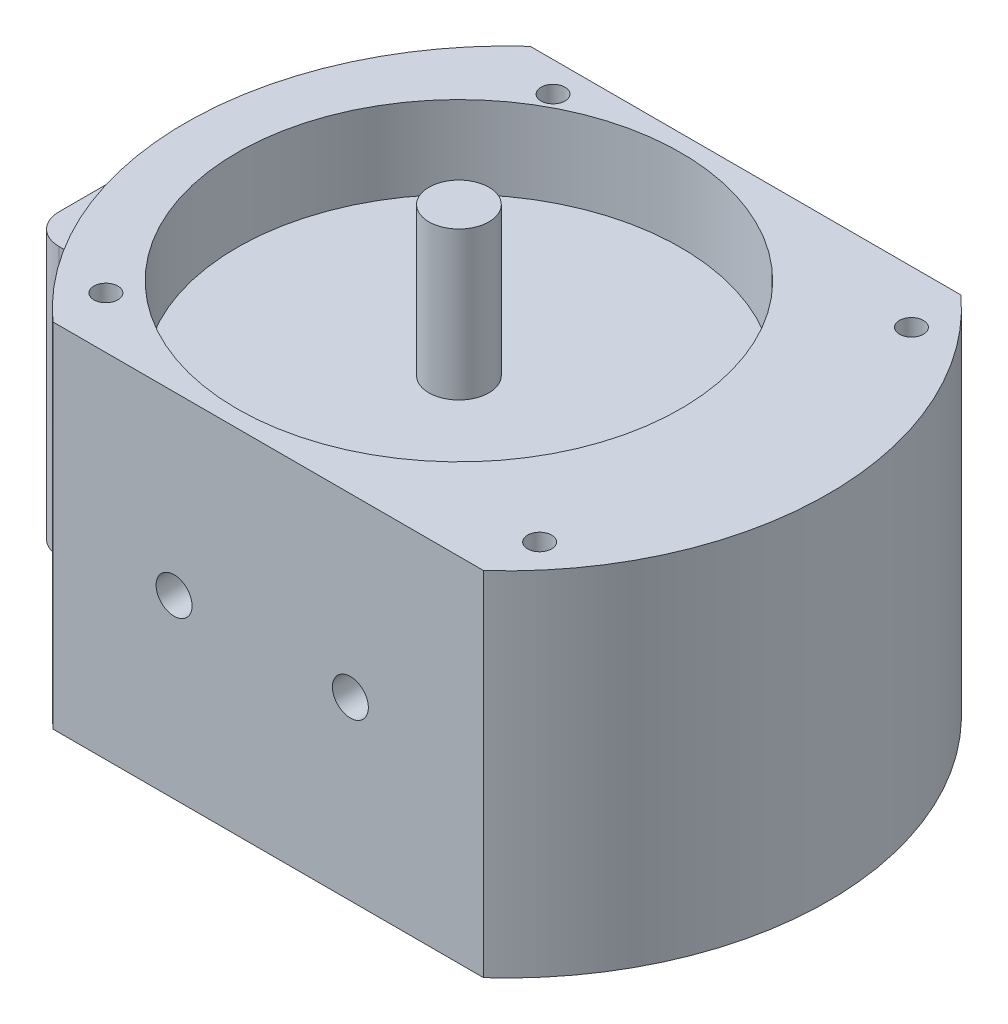
from build123d import *

# Parameters (mm, degrees)
BOSS_EXTRUDE1_DEPTH = 29.4
SKETCH2_R           = 18.5
CUT_EXTRUDE1_DEPTH  = 6.85
SKETCH3_R           = 2.5
BOSS_EXTRUDE2_DEPTH = 12.35
SKETCH4_R           = 2.85
BOSS_EXTRUDE3_DEPTH = 4
CUT_EXTRUDE3_DEPTH  = 7
SKETCH6_R           = 1.5
CUT_EXTRUDE4_DEPTH  = 40.8
SKETCH7_R           = 1
CUT_EXTRUDE5_DEPTH  = 35.9


with BuildPart() as part:
    # Sketch1 → Boss-Extrude1 (new body)
    with BuildSketch(Plane(origin=(0, 0, 0), x_dir=(1, 0, 0), z_dir=(0, 1, 0))):
        with BuildLine():
            Line((-13.950766, 19.9), (21.950766, 19.9))
            ThreePointArc((21.950766, 19.9), (30.8, 0), (21.950766, -19.9))
            Line((21.950766, -19.9), (-13.950766, -19.9))
            ThreePointArc((-13.950766, -19.9), (-18.785456749, -14.108967388), (-21.81472448, -7.2))
            Line((-21.81472448, -7.2), (-26.15, -7.2))
            ThreePointArc((-26.15, -7.2), (-27.917766953, -6.467766953), (-28.65, -4.7))
            Line((-28.65, -4.7), (-28.65, 14))
            ThreePointArc((-28.65, 14), (-27.917766953, 15.767766953), (-26.15, 16.5))
            Line((-26.15, 16.5), (-17.118475324, 16.5))
            ThreePointArc((-17.118475324, 16.5), (-15.608452372, 18.268787469), (-13.950766, 19.9))
        make_face()
    extrude(amount=BOSS_EXTRUDE1_DEPTH)

    # Sketch2 → Cut-Extrude1 (cut)
    with BuildSketch(Plane(origin=(0, 29.4, 0), x_dir=(1, 0, 0), z_dir=(0, 1, 0))):
        Circle(SKETCH2_R)
    extrude(amount=-CUT_EXTRUDE1_DEPTH, mode=Mode.SUBTRACT)

    # Sketch3 → Boss-Extrude2 (add)
    with BuildSketch(Plane(origin=(0, 22.55, 0), x_dir=(1, 0, 0), z_dir=(0, 1, 0))):
        Circle(SKETCH3_R)
    extrude(amount=BOSS_EXTRUDE2_DEPTH)

    # Sketch4 → Boss-Extrude3 (add)
    with BuildSketch(Plane.XZ):
        Circle(SKETCH4_R)
    extrude(amount=BOSS_EXTRUDE3_DEPTH)

    # Sketch5 → Cut-Extrude3 (cut)
    with BuildSketch(Plane(origin=(0, 29.4, 0), x_dir=(1, 0, 0), z_dir=(0, 1, 0))):
        with BuildLine():
            Line((-29.993194127, 17.400116254), (-16.38322728, 17.400116254))
            ThreePointArc((-16.38322728, 17.400116254), (-22.242311501, 5.438849795), (-21.619709811, -7.86577836))
            Line((-21.619709811, -7.86577836), (-29.993194127, -7.86577836))
            Line((-29.993194127, -7.86577836), (-29.993194127, 17.400116254))
        make_face()
    extrude(amount=-CUT_EXTRUDE3_DEPTH, mode=Mode.SUBTRACT)

    # Sketch6 → Cut-Extrude4 (cut, through all)
    with BuildSketch(Plane.XY.offset(19.9)):
        with Locations((-3.85, 14.7)):
            Circle(SKETCH6_R)
        with Locations((10.85, 14.7)):
            Circle(SKETCH6_R)
    extrude(amount=-CUT_EXTRUDE4_DEPTH, mode=Mode.SUBTRACT)

    # Sketch7 → Cut-Extrude5 (cut, through all)
    with BuildSketch(Plane.XZ):
        with Locations((-13.833383534, 15.6)):
            Circle(SKETCH7_R)
        with Locations((22.22970985, 15.5)):
            Circle(SKETCH7_R)
        with Locations((22.22970985, -15.5)):
            Circle(SKETCH7_R)
        with Locations((-9.553140845, -17.4)):
            Circle(SKETCH7_R)
    extrude(amount=-CUT_EXTRUDE5_DEPTH, mode=Mode.SUBTRACT)


solid = part.part
